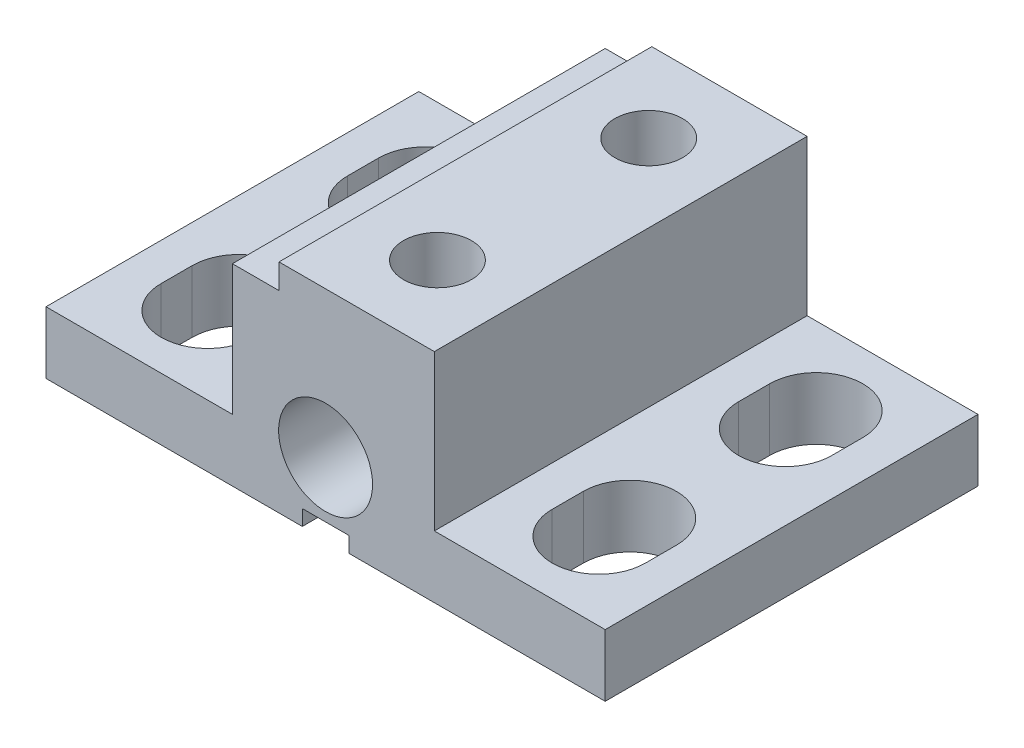
from build123d import *

# Parameters (mm, degrees)
SKETCH1_W                       = 18
SKETCH1_H                       = 12
EXTRUDE1_DEPTH                  = 2
SKETCH2_W                       = 1.5
SKETCH2_H                       = 0.5
EXTRUDE2_DEPTH                  = 13
EXTRUDE3_DEPTH                  = 3
MIRROR2_COPY_1_DEPTH            = 3
SKETCH4_W                       = 6.5
SKETCH4_H                       = 12
EXTRUDE4_DEPTH                  = 5
SKETCH5_W                       = 1.5
SKETCH5_H                       = 0.8
EXTRUDE5_DEPTH                  = 13
F_2_56_TAPPED_HOLE1_D           = 1.778
F_2_56_TAPPED_HOLE1_DEPTH       = 9.4488
F_2_56_TAPPED_HOLE1_CBORE_D     = 2.1844
F_2_56_TAPPED_HOLE1_CBORE_DEPTH = 5.5372
F_2_56_TAPPED_HOLE1_TIP         = 0.53416509
SKETCH7_R                       = 1.5113
EXTRUDE6_DEPTH                  = 3.0226


with BuildPart() as part:
    # Sketch1 → Extrude1 (new body)
    with BuildSketch(Plane(origin=(0, 0, 0), x_dir=(1, 0, 0), z_dir=(0, 1, 0))):
        with Locations((-9, 6)):
            Rectangle(SKETCH1_W, SKETCH1_H)
    extrude(amount=-EXTRUDE1_DEPTH)

    # Sketch2 → Extrude2 (cut, through all)
    with BuildSketch(Plane.XY):
        with Locations((-9, -1.75)):
            Rectangle(SKETCH2_W, SKETCH2_H)
    extrude(amount=-EXTRUDE2_DEPTH, mode=Mode.SUBTRACT)

    # Sketch3 → Extrude3 (cut, through all)
    with BuildSketch(Plane(origin=(0, 0, 0), x_dir=(1, 0, 0), z_dir=(0, 1, 0))):
        with BuildLine():
            Line((-16.793731354, 2.5), (-16.793731354, 3.5))
            ThreePointArc((-16.793731354, 3.5), (-15.293731354, 5), (-13.793731354, 3.5))
            Line((-13.793731354, 3.5), (-13.793731354, 2.5))
            ThreePointArc((-13.793731354, 2.5), (-15.293731354, 1), (-16.793731354, 2.5))
        make_face()
    extrude3 = extrude(amount=-EXTRUDE3_DEPTH, mode=Mode.SUBTRACT)

    # Mirror1: Extrude3 across plane
    add(extrude3.mirror(Plane(origin=(0, 0, -6), x_dir=(1, 0, 0), z_dir=(0, 0, -1))), mode=Mode.SUBTRACT)

    # Mirror2: Extrude3 across plane
    add(extrude3.mirror(Plane(origin=(-9, 0, 0), x_dir=(0, 0, 1), z_dir=(1, 0, 0))), mode=Mode.SUBTRACT)

    # Mirror2 copy 1 sketch → Mirror2 copy 1 (cut, through all)
    with BuildSketch(Plane(origin=(-18, 0, -12), x_dir=(-1, 0, 0), z_dir=(0, 1, 0))):
        with BuildLine():
            Line((-16.793731354, 2.5), (-16.793731354, 3.5))
            ThreePointArc((-16.793731354, 3.5), (-15.293731354, 5), (-13.793731354, 3.5))
            Line((-13.793731354, 3.5), (-13.793731354, 2.5))
            ThreePointArc((-13.793731354, 2.5), (-15.293731354, 1), (-16.793731354, 2.5))
        make_face()
    extrude(amount=-MIRROR2_COPY_1_DEPTH, mode=Mode.SUBTRACT)

    # Sketch4 → Extrude4 (add)
    with BuildSketch(Plane(origin=(0, 0, 0), x_dir=(1, 0, 0), z_dir=(0, 1, 0))):
        with Locations((-8.75, 6)):
            Rectangle(SKETCH4_W, SKETCH4_H)
    extrude(amount=EXTRUDE4_DEPTH)

    # Sketch5 → Extrude5 (cut, through all)
    with BuildSketch(Plane.XY):
        with Locations((-11.25, 4.6)):
            Rectangle(SKETCH5_W, SKETCH5_H)
    extrude(amount=-EXTRUDE5_DEPTH, mode=Mode.SUBTRACT)

    # #2-56 Tapped Hole1
    with Locations(Plane(origin=(-8, 5, -2.6), x_dir=(0, 0, 1), z_dir=(0, 1, 0))):
        with Locations((0, 0), (-6.8, 0)):
            CounterBoreHole(F_2_56_TAPPED_HOLE1_D / 2, F_2_56_TAPPED_HOLE1_CBORE_D / 2, F_2_56_TAPPED_HOLE1_CBORE_DEPTH, depth=F_2_56_TAPPED_HOLE1_DEPTH)
            with Locations((0, 0, -(F_2_56_TAPPED_HOLE1_DEPTH + F_2_56_TAPPED_HOLE1_TIP / 2))):  # 118° drill point
                Cone(0, F_2_56_TAPPED_HOLE1_D / 2, F_2_56_TAPPED_HOLE1_TIP, mode=Mode.SUBTRACT)

    # Sketch7 → Extrude6 (cut)
    with BuildSketch(Plane.XY):
        with Locations((-9, 0.3)):
            Circle(SKETCH7_R)
    extrude6 = extrude(amount=-EXTRUDE6_DEPTH, mode=Mode.SUBTRACT)

    # Mirror3: Extrude6 across plane
    add(extrude6.mirror(Plane(origin=(0, 0, -6), x_dir=(1, 0, 0), z_dir=(0, 0, -1))), mode=Mode.SUBTRACT)


solid = part.part
